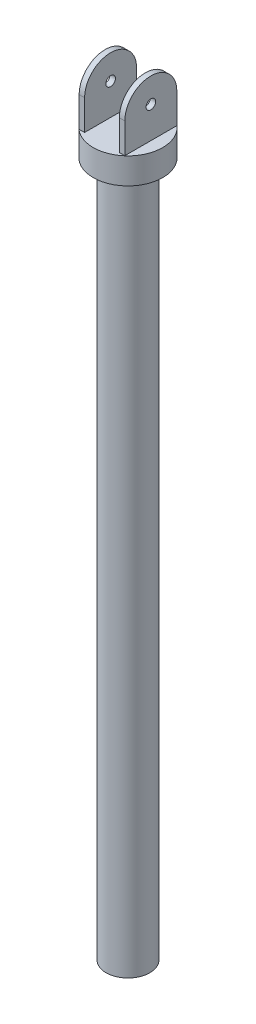
from build123d import *

# Parameters (mm, degrees)
SKETCH1_R           = 25.4
BOSS_EXTRUDE1_DEPTH = 19.05
SKETCH2_R           = 3.5
BOSS_EXTRUDE2_DEPTH = 4
SKETCH3_R           = 16
BOSS_EXTRUDE3_DEPTH = 508


with BuildPart() as part:
    # Sketch1 → Boss-Extrude1 (new body)
    with BuildSketch(Plane(origin=(0, 0, 0), x_dir=(1, 0, 0), z_dir=(0, 1, 0))):
        Circle(SKETCH1_R)
    extrude(amount=BOSS_EXTRUDE1_DEPTH)

    # Sketch2 → Boss-Extrude2 (add)
    with BuildSketch(Plane(origin=(12.7, 0, 0), x_dir=(0, 0, -1), z_dir=(1, 0, 0))):
        with BuildLine():
            Line((-19, 19.05), (19, 19.05))
            Line((19, 19.05), (19, 41.05))
            ThreePointArc((19, 41.05), (0, 60.05), (-19, 41.05))
            Line((-19, 41.05), (-19, 19.05))
        make_face()
        with Locations((0, 42.05)):
            Circle(SKETCH2_R, mode=Mode.SUBTRACT)
    boss_extrude2 = extrude(amount=BOSS_EXTRUDE2_DEPTH)

    # Mirror1: Boss-Extrude2 across plane
    add(boss_extrude2.mirror(Plane(origin=(0, 0, 0), x_dir=(0, 0, 1), z_dir=(1, 0, 0))))

    # Sketch3 → Boss-Extrude3 (add)
    with BuildSketch(Plane.XZ):
        Circle(SKETCH3_R)
    extrude(amount=BOSS_EXTRUDE3_DEPTH)


solid = part.part
